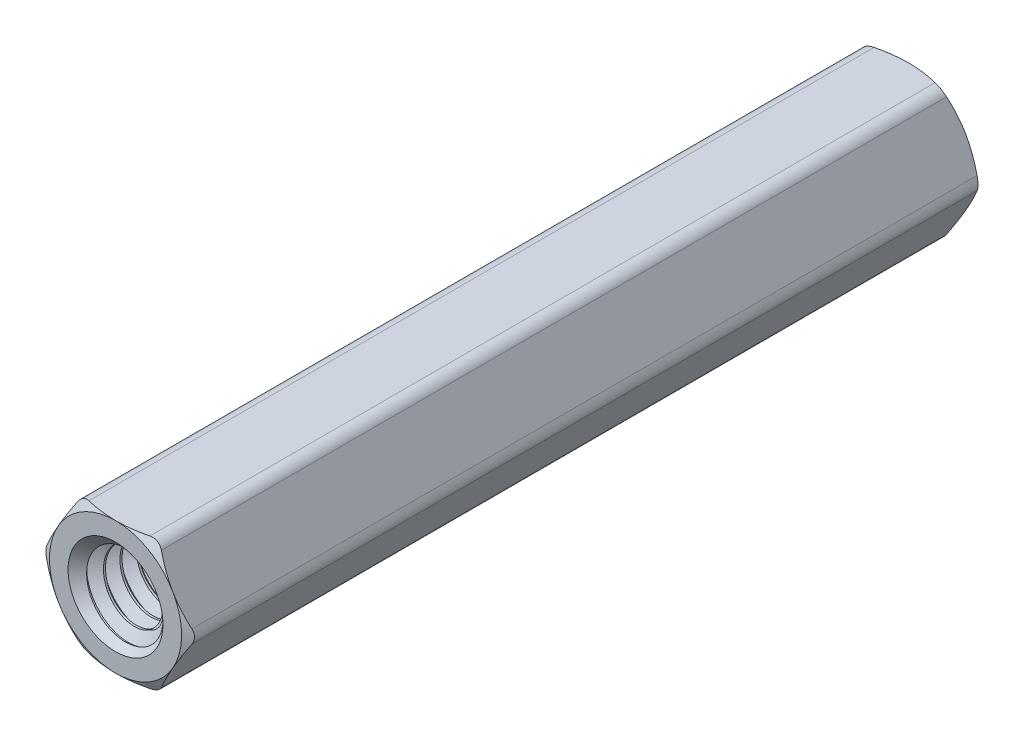
from build123d import *

# Parameters (mm, degrees)
SKETCH4_R              = 2.6289
BOSS_EXTRUDE1_DEPTH    = 19.05
SKETCH5_OUTSIDE_W      = 153.706
SKETCH5_OUTSIDE_H      = 152.724
SKETCH5_OUTSIDE_R      = 3.175
CUT_EXTRUDE1_DEPTH     = 39.407440143
CUT_EXTRUDE1_DRAFT     = -60
SKETCH6_OUTSIDE_W      = 153.706
SKETCH6_OUTSIDE_H      = 152.724
SKETCH6_OUTSIDE_R      = 3.175
CUT_EXTRUDE2_DEPTH     = 39.407440143
CUT_EXTRUDE2_DRAFT     = -60
FILLET1_R              = 0.635
BOSS_EXTRUDE2_START    = -9.525
SKETCH7_R              = 2.2812375
BOSS_EXTRUDE2_DEPTH    = 9.525
SKETCH8_W              = 9.525
SKETCH8_H              = 2.0828
CUT_SWEEP1_PITCH       = 0.79375
CUT_SWEEP1_HEIGHT      = 10.31875
CUT_SWEEP1_RADIUS      = 2.0828
CUT_SWEEP1_START_ANGLE = 90
CIRPATTERN1_COUNT      = 2


with BuildPart() as part:
    # Sketch3 → Revolve1 (revolve)
    with BuildSketch(Plane(origin=(0, 0, 0), x_dir=(0, 0, -1), z_dir=(1, 0, 0))):
        Polygon((-18.8515625, 2.0828), (-9.525, 2.0828), (-9.525, 0), (9.525, 0), (9.525, 2.0828), (19.05, 2.0828), (19.05, 3.175), (0, 3.175), (-19.05, 3.175), (-19.05, 2.2812375), align=None)
        Polygon((-18.8515625, 2.0828), (-9.525, 2.0828), (-9.525, 0), (9.525, 0), (9.525, 2.0828), (19.05, 2.0828), (19.05, 3.175), (0, 3.175), (-19.05, 3.175), (-19.05, 2.2812375), align=None)
    revolve(axis=Axis((0, 0, 9.525), (0, 0, 1)))

    # Sketch4 → Boss-Extrude1 (add, symmetric)
    with BuildSketch(Plane.XY):
        Polygon((-1.833087105, 3.175), (-3.666174209, 0), (-1.833087105, -3.175), (1.833087105, -3.175), (3.666174209, 0), (1.833087105, 3.175), align=None)
        Circle(SKETCH4_R, mode=Mode.SUBTRACT)
    extrude(amount=BOSS_EXTRUDE1_DEPTH, both=True)


with BuildPart() as cut_extrude1_tool:
    # Sketch5 outside → Cut-Extrude1 (with draft: the straight prism first)
    with BuildSketch(Plane.XY.offset(19.05)):
        Rectangle(SKETCH5_OUTSIDE_W, SKETCH5_OUTSIDE_H)
        Circle(SKETCH5_OUTSIDE_R, mode=Mode.SUBTRACT)
    extrude(amount=-CUT_EXTRUDE1_DEPTH)
    # Cut-Extrude1: the draft: its side faces are tilted about the plane it starts from
    cut_extrude1_sides = [cut_extrude1_tool.faces().sort_by_distance(p)[0] for p in [
        (0, -76.362, -0.653720071),
        (76.853, 0, -0.653720071),
        (0, 76.362, -0.653720071),
        (-76.853, 0, -0.653720071),
        (-3.175, 0, -0.653720071),
    ]]
    draft(cut_extrude1_sides, Plane.XY.offset(19.05), CUT_EXTRUDE1_DRAFT)


with BuildPart() as part_1:
    add(part.part)

    # Cut-Extrude1: cut by cut_extrude1_tool
    add(cut_extrude1_tool.part, mode=Mode.SUBTRACT)


with BuildPart() as cut_extrude2_tool:
    # Sketch6 outside → Cut-Extrude2 (with draft: the straight prism first)
    with BuildSketch(Plane(origin=(0, 0, -19.05), x_dir=(-1, 0, 0), z_dir=(0, 0, -1))):
        Rectangle(SKETCH6_OUTSIDE_W, SKETCH6_OUTSIDE_H)
        Circle(SKETCH6_OUTSIDE_R, mode=Mode.SUBTRACT)
    extrude(amount=-CUT_EXTRUDE2_DEPTH)
    # Cut-Extrude2: the draft: its side faces are tilted about the plane it starts from
    cut_extrude2_sides = [cut_extrude2_tool.faces().sort_by_distance(p)[0] for p in [
        (0, -76.362, 0.653720071),
        (-76.853, 0, 0.653720071),
        (0, 76.362, 0.653720071),
        (76.853, 0, 0.653720071),
        (3.175, 0, 0.653720071),
    ]]
    draft(cut_extrude2_sides, Plane(origin=(0, 0, -19.05), x_dir=(-1, 0, 0), z_dir=(0, 0, -1)), CUT_EXTRUDE2_DRAFT)


with BuildPart() as part_2:
    add(part_1.part)

    # Cut-Extrude2: cut by cut_extrude2_tool
    add(cut_extrude2_tool.part, mode=Mode.SUBTRACT)

    # Fillet1
    fillet1_edges = [part_2.edges().sort_by_distance(p)[0] for p in [
        (1.833087105, 3.175, 0),
        (-3.666174209, 0, 0),
        (-1.833087105, -3.175, 0),
        (1.833087105, -3.175, 0),
        (3.666174209, 0, 0),
        (-1.833087105, 3.175, 0),
    ]]
    fillet(fillet1_edges, radius=FILLET1_R)

    # Split1
    split(bisect_by=Plane.XY, keep=Keep.TOP)

    # Sketch7 → Boss-Extrude2 (add)
    with BuildSketch(Plane(origin=(0, 0, 9.525), x_dir=(-1, 0, 0), z_dir=(0, 0, -1)).offset(BOSS_EXTRUDE2_START)):
        Circle(SKETCH7_R)
    extrude(amount=BOSS_EXTRUDE2_DEPTH)


with BuildPart() as body_2:
    # Sketch8 → Revolve2 (revolve)
    with BuildSketch(Plane(origin=(0, 0, 0), x_dir=(0, 0, -1), z_dir=(1, 0, 0))):
        with Locations((-14.2875, 1.0414)):
            Rectangle(SKETCH8_W, SKETCH8_H)
    revolve(axis=Axis((0, 0, 9.525), (0, 0, 1)))

    # Cut-Sweep1: sweep along a helix
    with BuildLine() as cut_sweep1_path:
        add(Helix(CUT_SWEEP1_PITCH, CUT_SWEEP1_HEIGHT, CUT_SWEEP1_RADIUS, center=(0, 0, 19.05), direction=(0, 0, -1), mode=Mode.PRIVATE).rotate(Axis((0, 0, 19.05), (0, 0, -1)), CUT_SWEEP1_START_ANGLE))
    # Sketch10 → Cut-Sweep1 (sweep, cut)
    with BuildSketch(Plane(origin=(0, 0, 0), x_dir=(0, 0, -1), z_dir=(1, 0, 0))):
        Polygon((-19.446875, 1.567244252), (-19.34765625, 1.567244252), (-19.025195313, 2.125762979), (-19.769335938, 2.125762979), align=None)
    sweep(path=cut_sweep1_path.line, is_frenet=True, mode=Mode.SUBTRACT)


with BuildPart() as part_3:
    add(part_2.part)

    # Combine1: cut body 2
    add(body_2.part, mode=Mode.SUBTRACT)

    # Cut-Extrude3 cone 1 section (through the dimple's axis) → Cut-Extrude3 (revolve, cut)
    with BuildSketch(Plane(origin=(0, 0, 19.05), x_dir=(0, -1, 0), z_dir=(1, 0, 0))):
        Polygon((0, 0), (2.2812375, 0), (0, 2.2812375), align=None)
    revolve(axis=Axis((0, 0, 19.05), (0, 0, -1)), mode=Mode.SUBTRACT)


with BuildPart() as cirpattern1_1:
    # CirPattern1: pattern copy
    add(part_3.part.rotate(Axis((0, 0, 0), (1, 0, 0)), 1 * 360 / CIRPATTERN1_COUNT))


with BuildPart() as part_4:
    add(part_3.part)

    # Combine2: union CirPattern1_1
    add(cirpattern1_1.part)


solid = part_4.part
